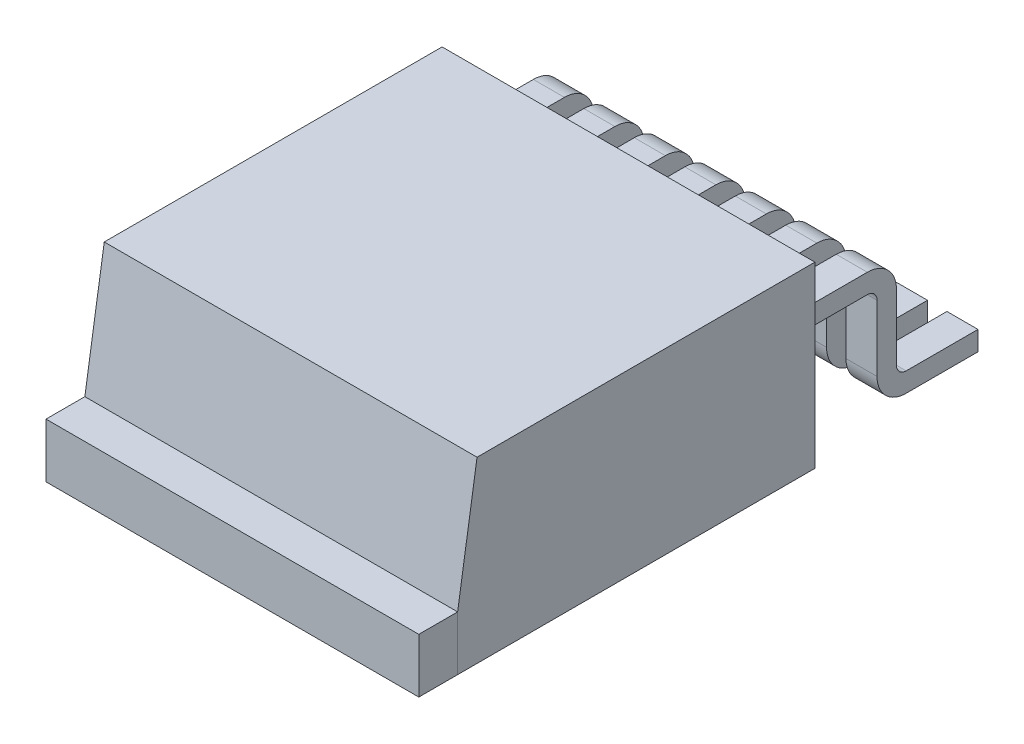
from build123d import *

# Parameters (mm, degrees)
BOSS_EXTRUDE1_DEPTH = 4.8
SKETCH2_W           = 9.6
SKETCH2_H           = 1.4
BOSS_EXTRUDE2_DEPTH = 1
SKETCH3_W           = 0.8
SKETCH3_H           = 0.5
BOSS_EXTRUDE3_DEPTH = 2.6
SKETCH4_W           = 0.8
SKETCH4_H           = 0.5
BOSS_EXTRUDE4_DEPTH = 3.2
SKETCH5_W           = 0.8
SKETCH5_H           = 0.5
BOSS_EXTRUDE5_DEPTH = 2.6
FILLET1_R           = 0.75
FILLET2_R           = 0.25
LPATTERN3_COUNT     = 7
LPATTERN3_PITCH     = 1.3


with BuildPart() as part:
    # Sketch1 → Boss-Extrude1 (new body, symmetric)
    with BuildSketch(Plane(origin=(0, 0, 0), x_dir=(0, 0, -1), z_dir=(1, 0, 0))):
        Polygon((4.6, 0), (4.6, 4.6), (-4.1, 4.6), (-4.6, 1.4), (-4.6, 0), align=None)
    extrude(amount=BOSS_EXTRUDE1_DEPTH, both=True)


with BuildPart() as body_2:
    # Sketch2 → Boss-Extrude2 (new body)
    with BuildSketch(Plane.XY.offset(4.6)):
        with Locations((0, 0.7)):
            Rectangle(SKETCH2_W, SKETCH2_H)
    extrude(amount=BOSS_EXTRUDE2_DEPTH)


with BuildPart() as body_3:
    # Sketch3 → Boss-Extrude3 (new body)
    with BuildSketch(Plane(origin=(0, 0, -4.6), x_dir=(-1, 0, 0), z_dir=(0, 0, -1))):
        with Locations((-3.9, 2.95)):
            Rectangle(SKETCH3_W, SKETCH3_H)
    extrude(amount=BOSS_EXTRUDE3_DEPTH)

    # Sketch4 → Boss-Extrude4 (add)
    with BuildSketch(Plane(origin=(0, 3.2, 0), x_dir=(1, 0, 0), z_dir=(0, 1, 0))):
        with Locations((3.9, 6.95)):
            Rectangle(SKETCH4_W, SKETCH4_H)
    extrude(amount=-BOSS_EXTRUDE4_DEPTH)

    # Sketch5 → Boss-Extrude5 (add)
    with BuildSketch(Plane.XY.offset(-6.7)):
        with Locations((3.9, 0.25)):
            Rectangle(SKETCH5_W, SKETCH5_H)
    extrude(amount=-BOSS_EXTRUDE5_DEPTH)

    # Fillet1
    fillet1_edges = [body_3.edges().sort_by_distance(p)[0] for p in [
        (3.9, 3.2, -7.2),
        (3.9, 0, -6.7),
    ]]
    fillet(fillet1_edges, radius=FILLET1_R)

    # Fillet2
    fillet2_edges = [body_3.edges().sort_by_distance(p)[0] for p in [
        (3.9, 2.7, -6.7),
        (3.9, 0.5, -7.2),
    ]]
    fillet(fillet2_edges, radius=FILLET2_R)


with BuildPart() as lpattern3_1:
    # LPattern3: pattern copy
    add(body_3.part.moved(Location(Vector(-1, 0, 0) * (1 * LPATTERN3_PITCH))))


with BuildPart() as lpattern3_2:
    # LPattern3: pattern copy
    add(body_3.part.moved(Location(Vector(-1, 0, 0) * (2 * LPATTERN3_PITCH))))


with BuildPart() as lpattern3_3:
    # LPattern3: pattern copy
    add(body_3.part.moved(Location(Vector(-1, 0, 0) * (3 * LPATTERN3_PITCH))))


with BuildPart() as lpattern3_4:
    # LPattern3: pattern copy
    add(body_3.part.moved(Location(Vector(-1, 0, 0) * (4 * LPATTERN3_PITCH))))


with BuildPart() as lpattern3_5:
    # LPattern3: pattern copy
    add(body_3.part.moved(Location(Vector(-1, 0, 0) * (5 * LPATTERN3_PITCH))))


with BuildPart() as lpattern3_6:
    # LPattern3: pattern copy
    add(body_3.part.moved(Location(Vector(-1, 0, 0) * (6 * LPATTERN3_PITCH))))


solid = Compound([part.part, body_2.part, body_3.part, lpattern3_1.part, lpattern3_2.part, lpattern3_3.part, lpattern3_4.part, lpattern3_5.part, lpattern3_6.part])
